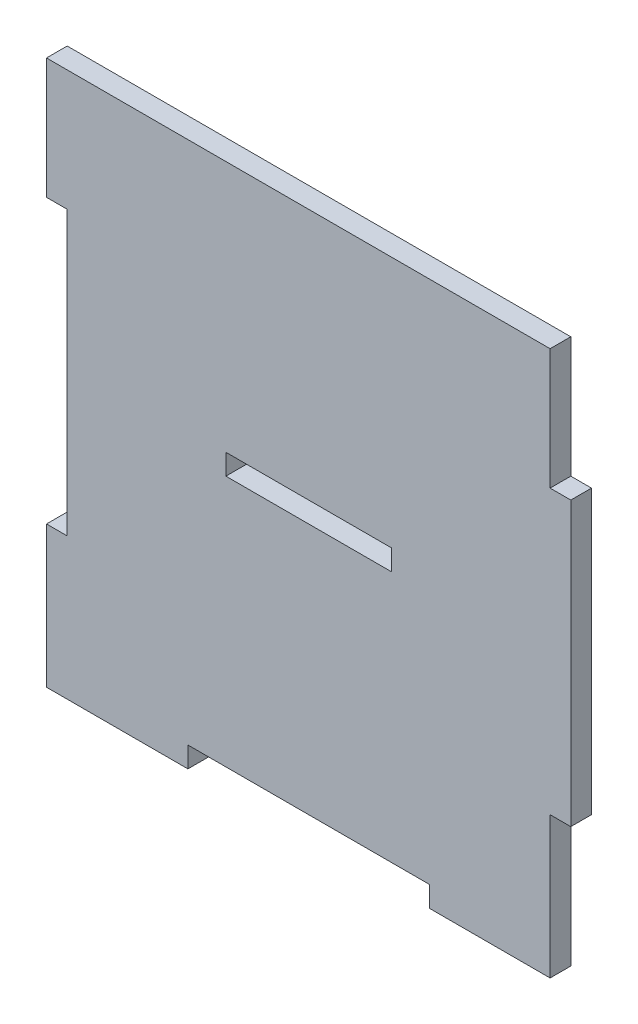
from build123d import *

# Parameters (mm, degrees)
BOSS_EXTRUDE1_DEPTH = 3
SKETCH2_W           = 24
SKETCH2_H           = 3
CUT_EXTRUDE1_DEPTH  = 3


with BuildPart() as part:
    # Sketch1 → Boss-Extrude1 (new body)
    with BuildSketch(Plane.XY):
        Polygon((-35, 38), (-17.5, 38), (17.5, 38), (35, 38), (35, 20.5), (38, 20.5), (38, -20.5), (35, -20.5), (35, -38), (35, -41), (17.5, -41), (17.5, -38), (-17.5, -38), (-17.5, -41), (-35, -41), (-38, -41), (-38, -38), (-38, -20.5), (-35, -20.5), (-35, 20.5), (-38, 20.5), (-38, 38), align=None)
    extrude(amount=BOSS_EXTRUDE1_DEPTH)

    # Sketch2 → Cut-Extrude1 (cut)
    with BuildSketch(Plane.XY.offset(3)):
        Rectangle(SKETCH2_W, SKETCH2_H)
    extrude(amount=-CUT_EXTRUDE1_DEPTH, mode=Mode.SUBTRACT)


solid = part.part
